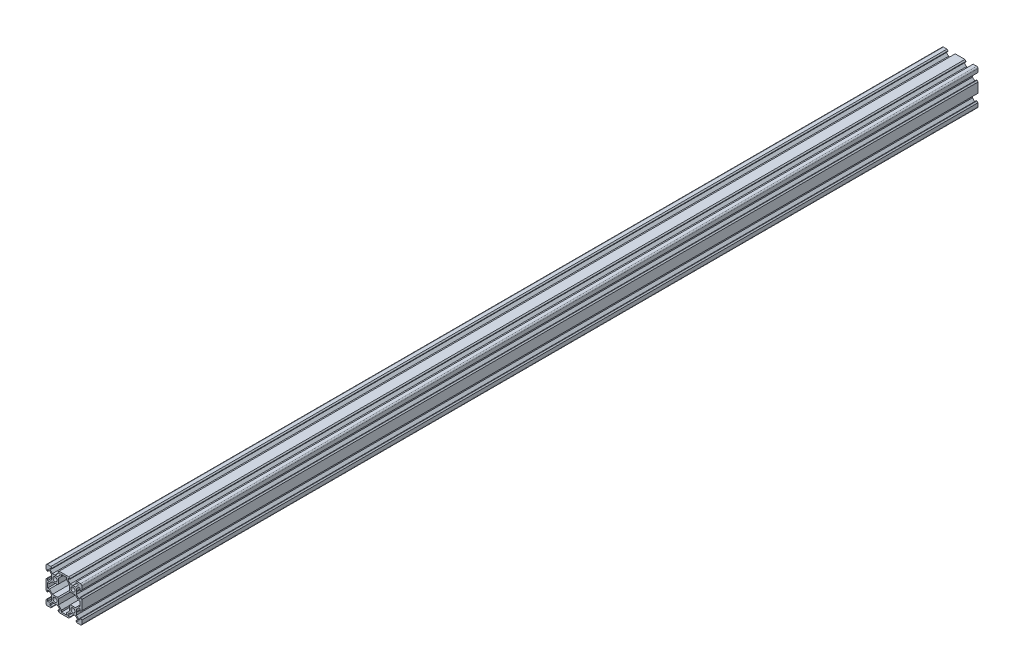
from build123d import *

# Parameters (mm, degrees)
SKETCH1_R           = 2.3
BOSS_EXTRUDE1_DEPTH = 1000


with BuildPart() as part:
    # Sketch1 → Boss-Extrude1 (new body)
    with BuildSketch(Plane.XY):
        with BuildLine():
            Line((14.58, -20), (18.5, -20))
            ThreePointArc((18.5, -20), (19.560660172, -19.560660172), (20, -18.5))
            Line((20, -18.5), (20, -14.58))
            Line((20, -14.58), (18.815, -13.395))
            Line((18.815, -13.395), (18.2, -13.395))
            Line((18.2, -13.395), (18.2, -15.5))
            Line((18.2, -15.5), (16.560660172, -15.5))
            Line((16.560660172, -15.5), (13.9, -12.839339828))
            Line((13.9, -12.839339828), (13.9, -10.21))
            Line((13.9, -10.21), (13.69, -10))
            Line((13.69, -10), (13.9, -9.79))
            Line((13.9, -9.79), (13.9, -7.160660172))
            Line((13.9, -7.160660172), (16.560660172, -4.5))
            Line((16.560660172, -4.5), (18.2, -4.5))
            Line((18.2, -4.5), (18.2, -6.605))
            Line((18.2, -6.605), (18.815, -6.605))
            Line((18.815, -6.605), (20, -5.42))
            Line((20, -5.42), (20, 5.42))
            Line((20, 5.42), (18.815, 6.605))
            Line((18.815, 6.605), (18.2, 6.605))
            Line((18.2, 6.605), (18.2, 4.5))
            Line((18.2, 4.5), (16.560660172, 4.5))
            Line((16.560660172, 4.5), (13.9, 7.160660172))
            Line((13.9, 7.160660172), (13.9, 9.79))
            Line((13.9, 9.79), (13.69, 10))
            Line((13.69, 10), (13.9, 10.21))
            Line((13.9, 10.21), (13.9, 12.839339828))
            Line((13.9, 12.839339828), (16.560660172, 15.5))
            Line((16.560660172, 15.5), (18.2, 15.5))
            Line((18.2, 15.5), (18.2, 13.395))
            Line((18.2, 13.395), (18.815, 13.395))
            Line((18.815, 13.395), (20, 14.58))
            Line((20, 14.58), (20, 18.5))
            ThreePointArc((20, 18.5), (19.560660172, 19.560660172), (18.5, 20))
            Line((18.5, 20), (14.58, 20))
            Line((14.58, 20), (13.395, 18.815))
            Line((13.395, 18.815), (13.395, 18.2))
            Line((13.395, 18.2), (15.5, 18.2))
            Line((15.5, 18.2), (15.5, 16.560660172))
            Line((15.5, 16.560660172), (12.839339828, 13.9))
            Line((12.839339828, 13.9), (10.21, 13.9))
            Line((10.21, 13.9), (10, 13.69))
            Line((10, 13.69), (9.79, 13.9))
            Line((9.79, 13.9), (7.160660172, 13.9))
            Line((7.160660172, 13.9), (4.5, 16.560660172))
            Line((4.5, 16.560660172), (4.5, 18.2))
            Line((4.5, 18.2), (6.605, 18.2))
            Line((6.605, 18.2), (6.605, 18.815))
            Line((6.605, 18.815), (5.42, 20))
            Line((5.42, 20), (-5.42, 20))
            Line((-5.42, 20), (-6.605, 18.815))
            Line((-6.605, 18.815), (-6.605, 18.2))
            Line((-6.605, 18.2), (-4.5, 18.2))
            Line((-4.5, 18.2), (-4.5, 16.560660172))
            Line((-4.5, 16.560660172), (-7.160660172, 13.9))
            Line((-7.160660172, 13.9), (-9.79, 13.9))
            Line((-9.79, 13.9), (-10, 13.69))
            Line((-10, 13.69), (-10.21, 13.9))
            Line((-10.21, 13.9), (-12.839339828, 13.9))
            Line((-12.839339828, 13.9), (-15.5, 16.560660172))
            Line((-15.5, 16.560660172), (-15.5, 18.2))
            Line((-15.5, 18.2), (-13.395, 18.2))
            Line((-13.395, 18.2), (-13.395, 18.815))
            Line((-13.395, 18.815), (-14.58, 20))
            Line((-14.58, 20), (-18.5, 20))
            ThreePointArc((-18.5, 20), (-19.560660172, 19.560660172), (-20, 18.5))
            Line((-20, 18.5), (-20, 14.58))
            Line((-20, 14.58), (-18.815, 13.395))
            Line((-18.815, 13.395), (-18.2, 13.395))
            Line((-18.2, 13.395), (-18.2, 15.5))
            Line((-18.2, 15.5), (-16.560660172, 15.5))
            Line((-16.560660172, 15.5), (-13.9, 12.839339828))
            Line((-13.9, 12.839339828), (-13.9, 10.21))
            Line((-13.9, 10.21), (-13.69, 10))
            Line((-13.69, 10), (-13.9, 9.79))
            Line((-13.9, 9.79), (-13.9, 7.160660172))
            Line((-13.9, 7.160660172), (-16.560660172, 4.5))
            Line((-16.560660172, 4.5), (-18.2, 4.5))
            Line((-18.2, 4.5), (-18.2, 6.605))
            Line((-18.2, 6.605), (-18.815, 6.605))
            Line((-18.815, 6.605), (-20, 5.42))
            Line((-20, 5.42), (-20, -5.42))
            Line((-20, -5.42), (-18.815, -6.605))
            Line((-18.815, -6.605), (-18.2, -6.605))
            Line((-18.2, -6.605), (-18.2, -4.5))
            Line((-18.2, -4.5), (-16.560660172, -4.5))
            Line((-16.560660172, -4.5), (-13.9, -7.160660172))
            Line((-13.9, -7.160660172), (-13.9, -9.79))
            Line((-13.9, -9.79), (-13.69, -10))
            Line((-13.69, -10), (-13.9, -10.21))
            Line((-13.9, -10.21), (-13.9, -12.839339828))
            Line((-13.9, -12.839339828), (-16.560660172, -15.5))
            Line((-16.560660172, -15.5), (-18.2, -15.5))
            Line((-18.2, -15.5), (-18.2, -13.395))
            Line((-18.2, -13.395), (-18.815, -13.395))
            Line((-18.815, -13.395), (-20, -14.58))
            Line((-20, -14.58), (-20, -18.5))
            ThreePointArc((-20, -18.5), (-19.560660172, -19.560660172), (-18.5, -20))
            Line((-18.5, -20), (-14.58, -20))
            Line((-14.58, -20), (-13.395, -18.815))
            Line((-13.395, -18.815), (-13.395, -18.2))
            Line((-13.395, -18.2), (-15.5, -18.2))
            Line((-15.5, -18.2), (-15.5, -16.560660172))
            Line((-15.5, -16.560660172), (-12.839339828, -13.9))
            Line((-12.839339828, -13.9), (-10.21, -13.9))
            Line((-10.21, -13.9), (-10, -13.69))
            Line((-10, -13.69), (-9.79, -13.9))
            Line((-9.79, -13.9), (-7.160660172, -13.9))
            Line((-7.160660172, -13.9), (-4.5, -16.560660172))
            Line((-4.5, -16.560660172), (-4.5, -18.2))
            Line((-4.5, -18.2), (-6.605, -18.2))
            Line((-6.605, -18.2), (-6.605, -18.815))
            Line((-6.605, -18.815), (-5.42, -20))
            Line((-5.42, -20), (5.42, -20))
            Line((5.42, -20), (6.605, -18.815))
            Line((6.605, -18.815), (6.605, -18.2))
            Line((6.605, -18.2), (4.5, -18.2))
            Line((4.5, -18.2), (4.5, -16.560660172))
            Line((4.5, -16.560660172), (7.160660172, -13.9))
            Line((7.160660172, -13.9), (9.79, -13.9))
            Line((9.79, -13.9), (10, -13.69))
            Line((10, -13.69), (10.21, -13.9))
            Line((10.21, -13.9), (12.839339828, -13.9))
            Line((12.839339828, -13.9), (15.5, -16.560660172))
            Line((15.5, -16.560660172), (15.5, -18.2))
            Line((15.5, -18.2), (13.395, -18.2))
            Line((13.395, -18.2), (13.395, -18.815))
            Line((13.395, -18.815), (14.58, -20))
        make_face()
        with Locations((-10, -10)):
            Circle(SKETCH1_R, mode=Mode.SUBTRACT)
        with Locations((10, -10)):
            Circle(SKETCH1_R, mode=Mode.SUBTRACT)
        Polygon((-16.239339828, -2.7), (-18.2, -2.7), (-18.2, 2.7), (-16.239339828, 2.7), (-12.839339828, 6.1), (-7.160660172, 6.1), (-6.1, 7.160660172), (-6.1, 12.839339828), (-2.7, 16.239339828), (-2.7, 18.2), (2.7, 18.2), (2.7, 16.239339828), (6.1, 12.839339828), (6.1, 7.160660172), (7.160660172, 6.1), (12.839339828, 6.1), (16.239339828, 2.7), (18.2, 2.7), (18.2, -2.7), (16.239339828, -2.7), (12.839339828, -6.1), (7.160660172, -6.1), (6.1, -7.160660172), (6.1, -12.839339828), (2.7, -16.239339828), (2.7, -18.2), (-2.7, -18.2), (-2.7, -16.239339828), (-6.1, -12.839339828), (-6.1, -7.160660172), (-7.160660172, -6.1), (-12.839339828, -6.1), align=None, mode=Mode.SUBTRACT)
        with Locations((-10, 10)):
            Circle(SKETCH1_R, mode=Mode.SUBTRACT)
        with Locations((10, 10)):
            Circle(SKETCH1_R, mode=Mode.SUBTRACT)
    extrude(amount=BOSS_EXTRUDE1_DEPTH)


solid = part.part
